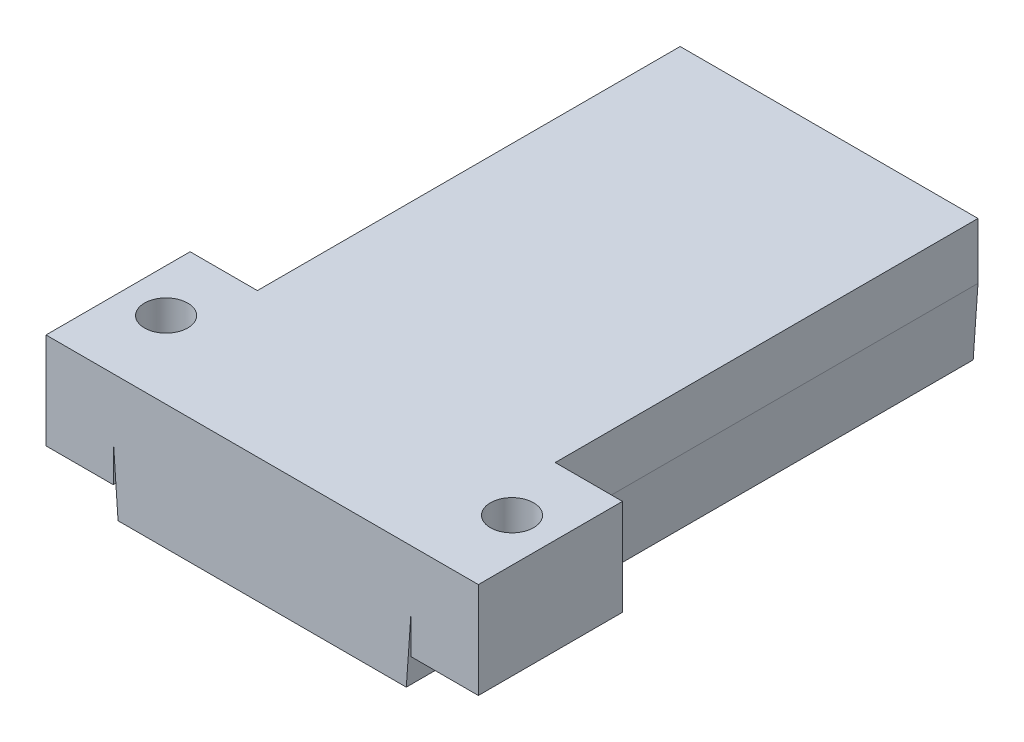
from build123d import *

# Parameters (mm, degrees)
SKETCH1_W           = 26
SKETCH1_H           = 53
SKETCH1_W_2         = 20
SKETCH1_H_2         = 10
BOSS_EXTRUDE1_DEPTH = 5
SKETCH2_W           = 31
SKETCH2_H           = 59
SKETCH2_W_2         = 26
SKETCH2_H_2         = 53
BOSS_EXTRUDE2_DEPTH = 10
SKETCH3_W           = 31
SKETCH3_H           = 59
BOSS_EXTRUDE3_DEPTH = 3
CHAMFER1_SIZE       = 0.5
CHAMFER1_SIZE2      = 7.150333128
SKETCH10_W          = 7
SKETCH10_H          = 15
SKETCH10_R          = 2.25
BOSS_EXTRUDE7_DEPTH = 10


with BuildPart() as part:
    # Sketch1 → Boss-Extrude1 (new body)
    with BuildSketch(Plane(origin=(0, 0, 0), x_dir=(1, 0, 0), z_dir=(0, 1, 0))):
        with Locations((-13, 26.5)):
            Rectangle(SKETCH1_W, SKETCH1_H)
        with Locations((-13, 27)):
            Rectangle(SKETCH1_W_2, SKETCH1_H_2, mode=Mode.SUBTRACT)
        with Locations((-13, 43)):
            Rectangle(SKETCH1_W_2, SKETCH1_H_2, mode=Mode.SUBTRACT)
        with Locations((-13, 11)):
            Rectangle(SKETCH1_W_2, SKETCH1_H_2, mode=Mode.SUBTRACT)
    extrude(amount=BOSS_EXTRUDE1_DEPTH)

    # Sketch2 → Boss-Extrude2 (add)
    with BuildSketch(Plane(origin=(0, 5, 0), x_dir=(1, 0, 0), z_dir=(0, 1, 0))):
        with Locations((-13, 26.5)):
            Rectangle(SKETCH2_W, SKETCH2_H)
        with Locations((-13, 26.5)):
            Rectangle(SKETCH2_W_2, SKETCH2_H_2, mode=Mode.SUBTRACT)
    extrude(amount=-BOSS_EXTRUDE2_DEPTH)

    # Sketch3 → Boss-Extrude3 (add)
    with BuildSketch(Plane(origin=(0, 5, 0), x_dir=(1, 0, 0), z_dir=(0, 1, 0))):
        with Locations((-13, 26.5)):
            Rectangle(SKETCH3_W, SKETCH3_H)
    extrude(amount=BOSS_EXTRUDE3_DEPTH)

    # Chamfer1
    chamfer1_edges = [part.edges().sort_by_distance(p)[0] for p in [
        (-28.5, -5, -26.5),
        (2.5, -5, -26.5),
    ]]
    chamfer1_side = [part.faces().sort_by_distance(p)[0] for p in [
        (-13, -5, -55.333516692),
    ]]
    chamfer(chamfer1_edges, length=CHAMFER1_SIZE, length2=CHAMFER1_SIZE2, reference=chamfer1_side[0])

    # Sketch10 → Boss-Extrude7 (add)
    with BuildSketch(Plane(origin=(0, 8, 0), x_dir=(1, 0, 0), z_dir=(0, 1, 0))):
        with Locations((6, 4.5)):
            Rectangle(SKETCH10_W, SKETCH10_H)
        with Locations((5, 5)):
            Circle(SKETCH10_R, mode=Mode.SUBTRACT)
        with Locations((-32, 4.5)):
            Rectangle(SKETCH10_W, SKETCH10_H)
        with Locations((-31, 5)):
            Circle(SKETCH10_R, mode=Mode.SUBTRACT)
    extrude(amount=-BOSS_EXTRUDE7_DEPTH)


solid = part.part
